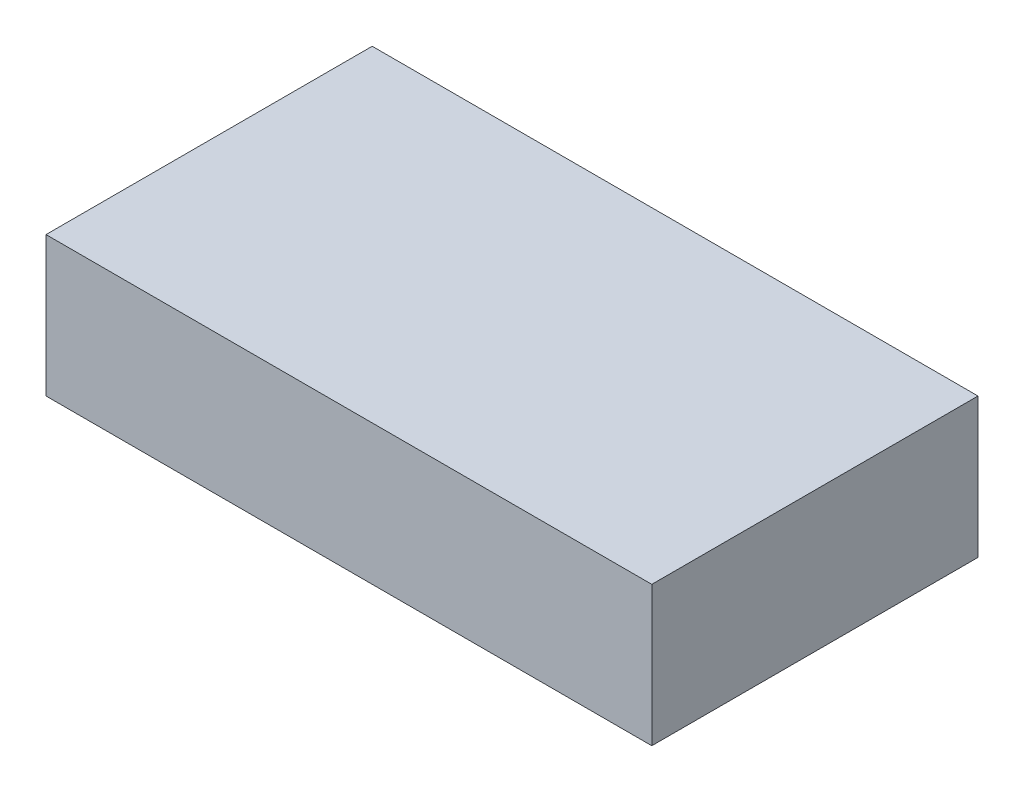
from build123d import *

# Parameters (mm, degrees)
SKETCH1_W           = 165.1
SKETCH1_H           = 88.9
BOSS_EXTRUDE1_DEPTH = 38.1


with BuildPart() as part:
    # Sketch1 → Boss-Extrude1 (new body)
    with BuildSketch(Plane(origin=(0, 0, 0), x_dir=(1, 0, 0), z_dir=(0, 1, 0))):
        with Locations((82.55, -44.45)):
            Rectangle(SKETCH1_W, SKETCH1_H)
    extrude(amount=BOSS_EXTRUDE1_DEPTH)


solid = part.part
